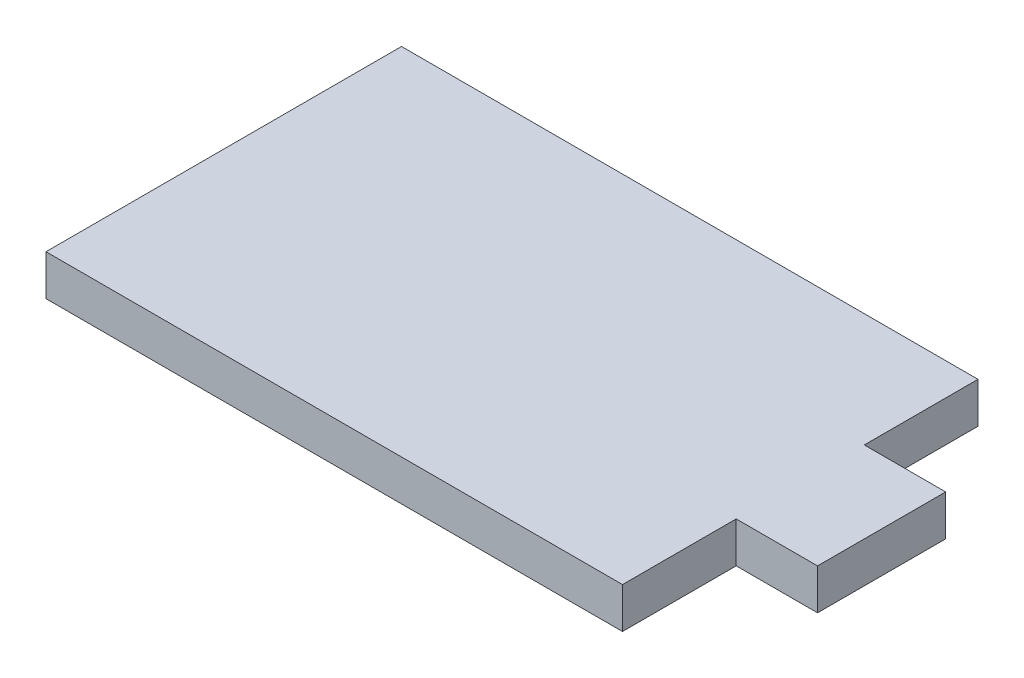
from build123d import *

# Parameters (mm, degrees)
BOSS_EXTRUDE1_DEPTH = 3.175


with BuildPart() as part:
    # Sketch1 → Boss-Extrude1 (new body)
    with BuildSketch(Plane(origin=(0, 0, 0), x_dir=(1, 0, 0), z_dir=(0, 1, 0))):
        Polygon((-22.5, 0), (-22.5, 8.875), (22.5, 8.875), (22.5, 0), (28.85, 0), (28.85, -10), (22.5, -10), (22.5, -18.875), (-22.5, -18.875), (-22.5, -10), align=None)
    extrude(amount=BOSS_EXTRUDE1_DEPTH)


solid = part.part
